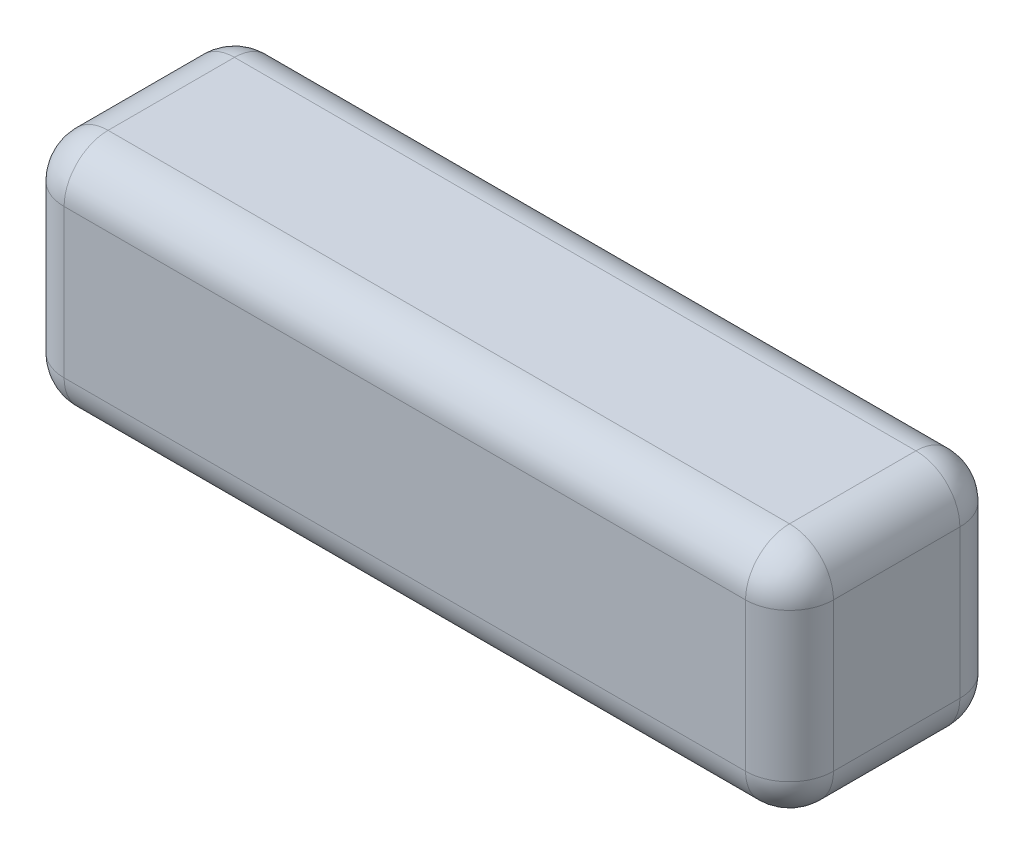
from build123d import *

# Parameters (mm, degrees)
SKETCH1_W           = 140
SKETCH1_H           = 39
BOSS_EXTRUDE1_DEPTH = 43
FILLET1_R           = 8


with BuildPart() as part:
    # Sketch1 → Boss-Extrude1 (new body)
    with BuildSketch(Plane(origin=(0, 0, 0), x_dir=(1, 0, 0), z_dir=(0, 1, 0))):
        with Locations((70, -19.5)):
            Rectangle(SKETCH1_W, SKETCH1_H)
    extrude(amount=BOSS_EXTRUDE1_DEPTH)

    # Fillet1
    fillet1_edges = [part.edges().sort_by_distance(p)[0] for p in [
        (140, 43, 19.5),
        (70, 43, 0),
        (0, 43, 19.5),
        (70, 0, 0),
        (140, 0, 19.5),
        (70, 0, 39),
        (0, 0, 19.5),
        (0, 21.5, 0),
        (140, 21.5, 0),
        (140, 21.5, 39),
        (0, 21.5, 39),
        (70, 43, 39),
    ]]
    fillet(fillet1_edges, radius=FILLET1_R)


solid = part.part
